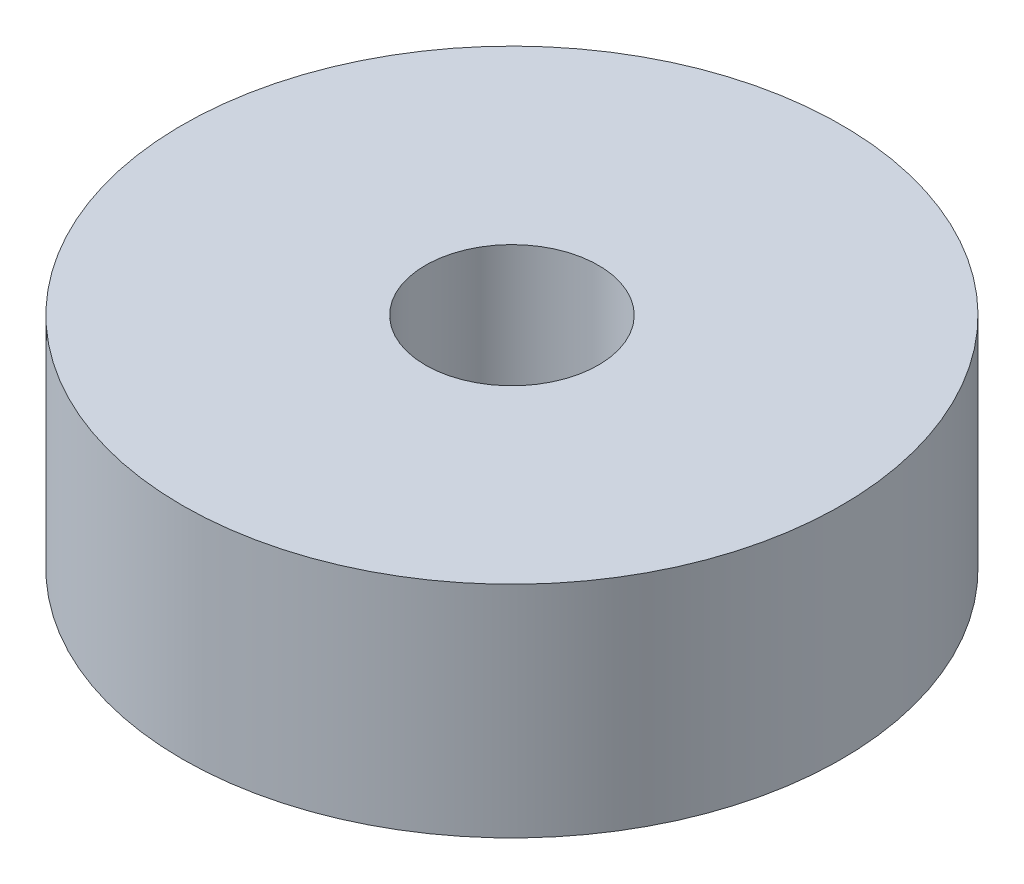
from build123d import *

# Parameters (mm, degrees)
SKETCH1_R           = 19.05
SKETCH1_R_2         = 5
BOSS_EXTRUDE1_DEPTH = 12.7


with BuildPart() as part:
    # Sketch1 → Boss-Extrude1 (new body)
    with BuildSketch(Plane(origin=(0, 0, 0), x_dir=(1, 0, 0), z_dir=(0, 1, 0))):
        Circle(SKETCH1_R)
        Circle(SKETCH1_R_2, mode=Mode.SUBTRACT)
    extrude(amount=BOSS_EXTRUDE1_DEPTH)


solid = part.part
